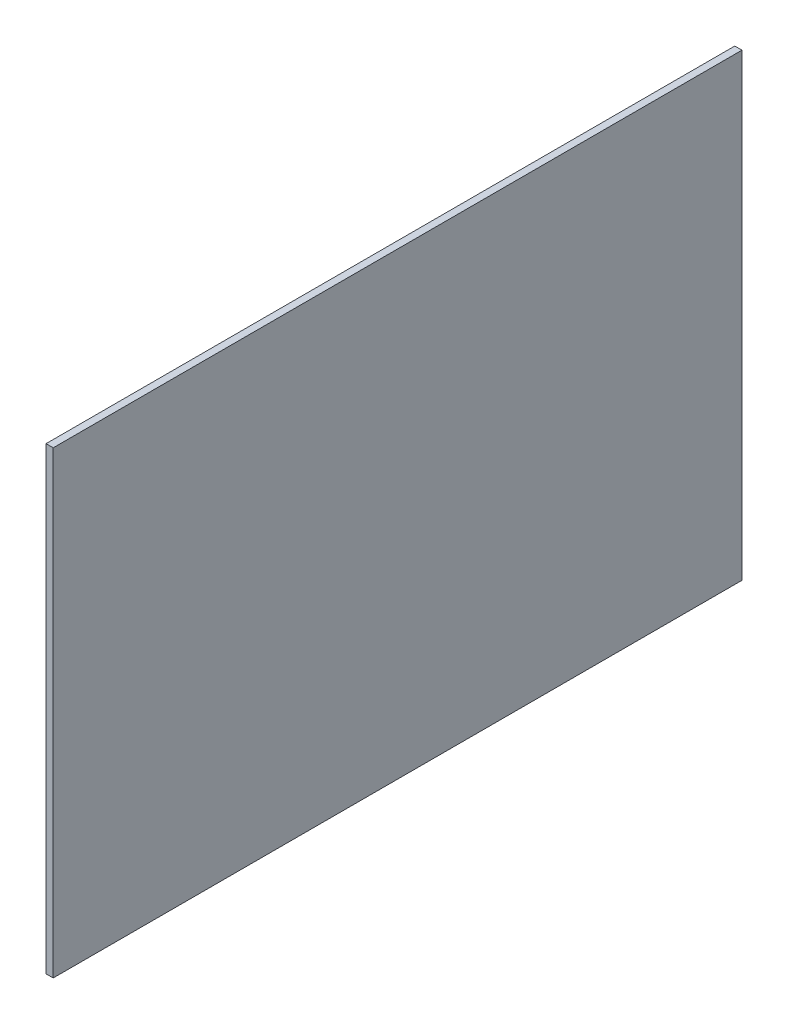
from build123d import *

# Parameters (mm, degrees)
SKETCH1_W           = 76.2
SKETCH1_H           = 50.8
BOSS_EXTRUDE1_DEPTH = 0.79375


with BuildPart() as part:
    # Sketch1 → Boss-Extrude1 (new body)
    with BuildSketch(Plane(origin=(0, 0, 0), x_dir=(0, 0, -1), z_dir=(1, 0, 0))):
        with Locations((38.1, 25.4)):
            Rectangle(SKETCH1_W, SKETCH1_H)
    extrude(amount=BOSS_EXTRUDE1_DEPTH)


solid = part.part
